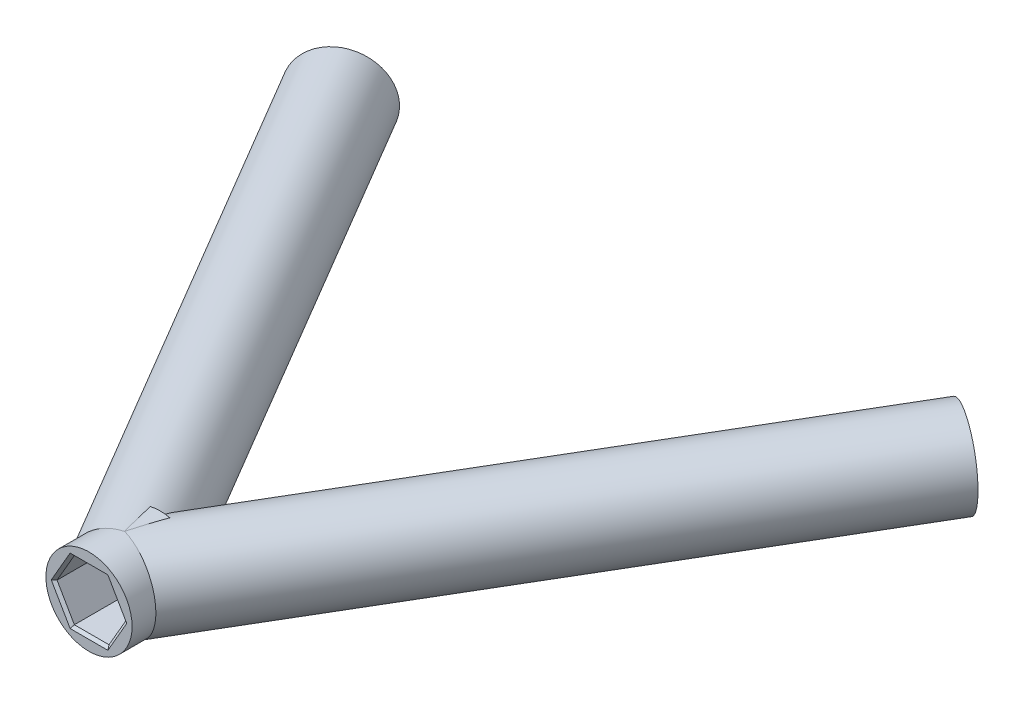
from build123d import *

# Parameters (mm, degrees)
SKETCH1_W          = 4
SKETCH1_H          = 6.6
CUT_EXTRUDE1_DEPTH = 6.6
CUT_EXTRUDE2_DEPTH = 6.6
CUT_EXTRUDE3_DEPTH = 6.6
CHAMFER1_SIZE      = 0.25


with BuildPart() as part:
    # Sketch1 → Revolve-Thin1 (revolve)
    with BuildSketch(Plane(origin=(0, 0, 0), x_dir=(1, 0, 0), z_dir=(0, 1, 0)), mode=Mode.PRIVATE) as revolve_thin1_sk:
        with Locations((-2, 20.8)):
            Rectangle(SKETCH1_W, SKETCH1_H)
    revolve(revolve_thin1_sk.sketch.rotate(Axis((0, 0, 0), (0, 0, -1)), 180), axis=Axis((0, 0, 0), (0, 0, -1)))

    # Sketch3 → Revolve-Thin2 (revolve)
    with BuildSketch(Plane(origin=(0, 0, 0), x_dir=(1, 0, 0), z_dir=(0, 1, 0)), mode=Mode.PRIVATE) as revolve_thin2_sk:
        Polygon((-28.888127, 69.742108), (0, 20.8), (3.444699, 22.833237), (-25.443428, 71.775345), align=None)
    revolve(revolve_thin2_sk.sketch.rotate(Axis((-28.888127, 0, -69.742108), (0.5083091776235522, 0, 0.8611746512430961)), 180), axis=Axis((-28.888127, 0, -69.742108), (0.5083091776235522, 0, 0.8611746512430961)))

    # Sketch4 → Revolve-Thin3 (revolve)
    with BuildSketch(Plane(origin=(0, 0, 0), x_dir=(1, 0, 0), z_dir=(0, 1, 0)), mode=Mode.PRIVATE) as revolve_thin3_sk:
        Polygon((0, 20.8), (28.888127, 69.742108), (25.443428, 71.775345), (-3.444699, 22.833237), align=None)
    revolve(revolve_thin3_sk.sketch.rotate(Axis((0, 0, -20.8), (0.5083091776235522, 0, -0.8611746512430961)), 180), axis=Axis((0, 0, -20.8), (0.5083091776235522, 0, -0.8611746512430961)))

    # Sketch5 → Cut-Extrude1 (cut)
    with BuildSketch(Plane(origin=(-37.993181, 0, -64.367841), x_dir=(-0.861174651243096, 0, 0.5083091776235522), z_dir=(-0.5083091776235522, 0, -0.861174651243096))):
        Polygon((-8.96491, 2.785), (-12.180751, 2.785), (-13.788672, 0), (-12.180751, -2.785), (-8.96491, -2.785), (-7.35699, 0), align=None)
    extrude(amount=-CUT_EXTRUDE1_DEPTH, mode=Mode.SUBTRACT)

    # Sketch6 → Cut-Extrude2 (cut)
    with BuildSketch(Plane.XY.offset(-17.5)):
        Polygon((1.60792, 2.785), (-1.60792, 2.785), (-3.215841, 0), (-1.60792, -2.785), (1.60792, -2.785), (3.215841, 0), align=None)
    extrude(amount=-CUT_EXTRUDE2_DEPTH, mode=Mode.SUBTRACT)

    # Sketch7 → Cut-Extrude3 (cut)
    with BuildSketch(Plane(origin=(37.993181, 0, -64.367841), x_dir=(-0.861174651243096, 0, -0.5083091776235522), z_dir=(0.5083091776235522, 0, -0.861174651243096))):
        Polygon((12.180751, 2.785), (8.96491, 2.785), (7.35699, 0), (8.96491, -2.785), (12.180751, -2.785), (13.788672, 0), align=None)
    extrude(amount=-CUT_EXTRUDE3_DEPTH, mode=Mode.SUBTRACT)

    # Chamfer1
    chamfer1_edges = [part.edges().sort_by_distance(p)[0] for p in [
        (-30.965178, 1.3925, -68.516127),
        (-28.888127, 2.785, -69.742108),
        (-26.811077, 1.3925, -70.968089),
        (-26.811077, -1.3925, -70.968089),
        (-28.888127, -2.785, -69.742108),
        (-30.965178, -1.3925, -68.516127),
        (2.411881, 1.3925, -17.5),
        (0, 2.785, -17.5),
        (-2.411881, 1.3925, -17.5),
        (-2.411881, -1.3925, -17.5),
        (0, -2.785, -17.5),
        (2.411881, -1.3925, -17.5),
        (26.811077, 1.3925, -70.968089),
        (28.888127, 2.785, -69.742108),
        (30.965178, 1.3925, -68.516127),
        (30.965178, -1.3925, -68.516127),
        (28.888127, -2.785, -69.742108),
        (26.811077, -1.3925, -70.968089),
    ]]
    chamfer(chamfer1_edges, length=CHAMFER1_SIZE)


solid = part.part
